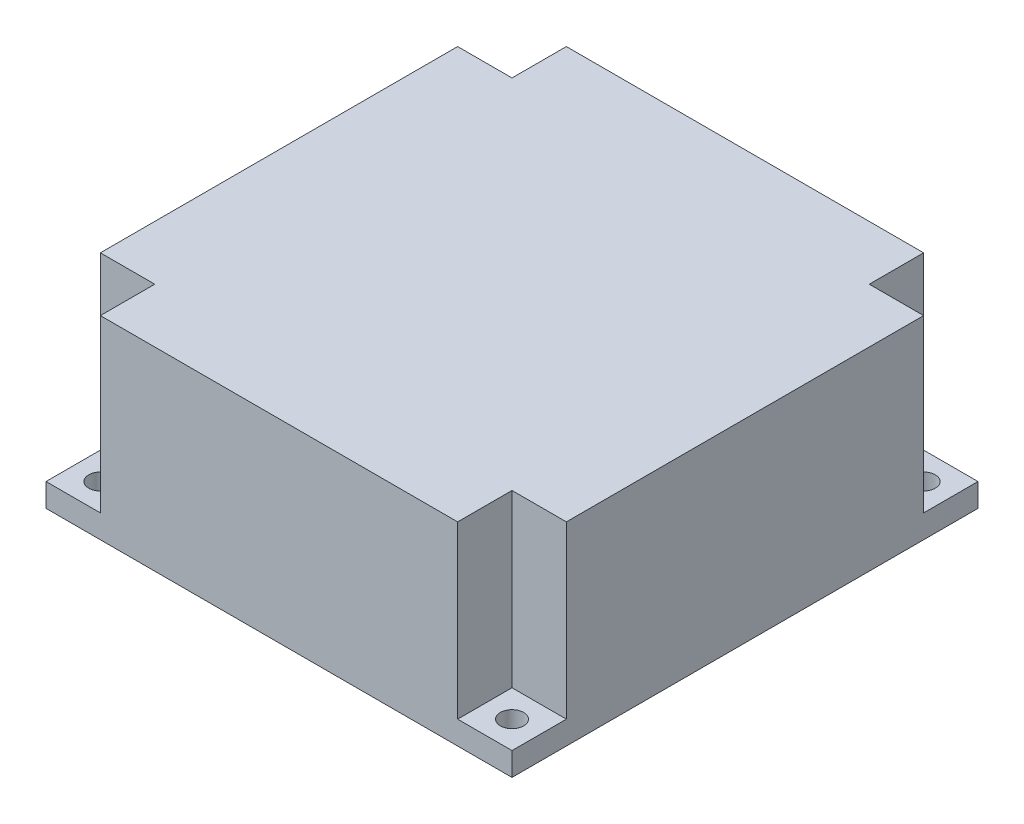
from build123d import *

# Parameters (mm, degrees)
SKETCH1_W           = 60
SKETCH1_H           = 60
SKETCH1_R           = 1.5
BOSS_EXTRUDE1_DEPTH = 3
BOSS_EXTRUDE2_DEPTH = 22


with BuildPart() as part:
    # Sketch1 → Boss-Extrude1 (new body)
    with BuildSketch(Plane(origin=(0, 0, 0), x_dir=(1, 0, 0), z_dir=(0, 1, 0))):
        with Locations((30, 30)):
            Rectangle(SKETCH1_W, SKETCH1_H)
        with Locations((3.5, 3.5)):
            Circle(SKETCH1_R, mode=Mode.SUBTRACT)
        with Locations((56.5, 3.5)):
            Circle(SKETCH1_R, mode=Mode.SUBTRACT)
        with Locations((56.5, 56.5)):
            Circle(SKETCH1_R, mode=Mode.SUBTRACT)
        with Locations((3.5, 56.5)):
            Circle(SKETCH1_R, mode=Mode.SUBTRACT)
    extrude(amount=BOSS_EXTRUDE1_DEPTH)

    # Sketch2 → Boss-Extrude2 (add)
    with BuildSketch(Plane(origin=(0, 3, 0), x_dir=(1, 0, 0), z_dir=(0, 1, 0))):
        Polygon((7, 60), (53, 60), (53, 53), (60, 53), (60, 7), (53, 7), (53, 0), (7, 0), (7, 7), (0, 7), (0, 53), (7, 53), align=None)
    extrude(amount=BOSS_EXTRUDE2_DEPTH)


solid = part.part
